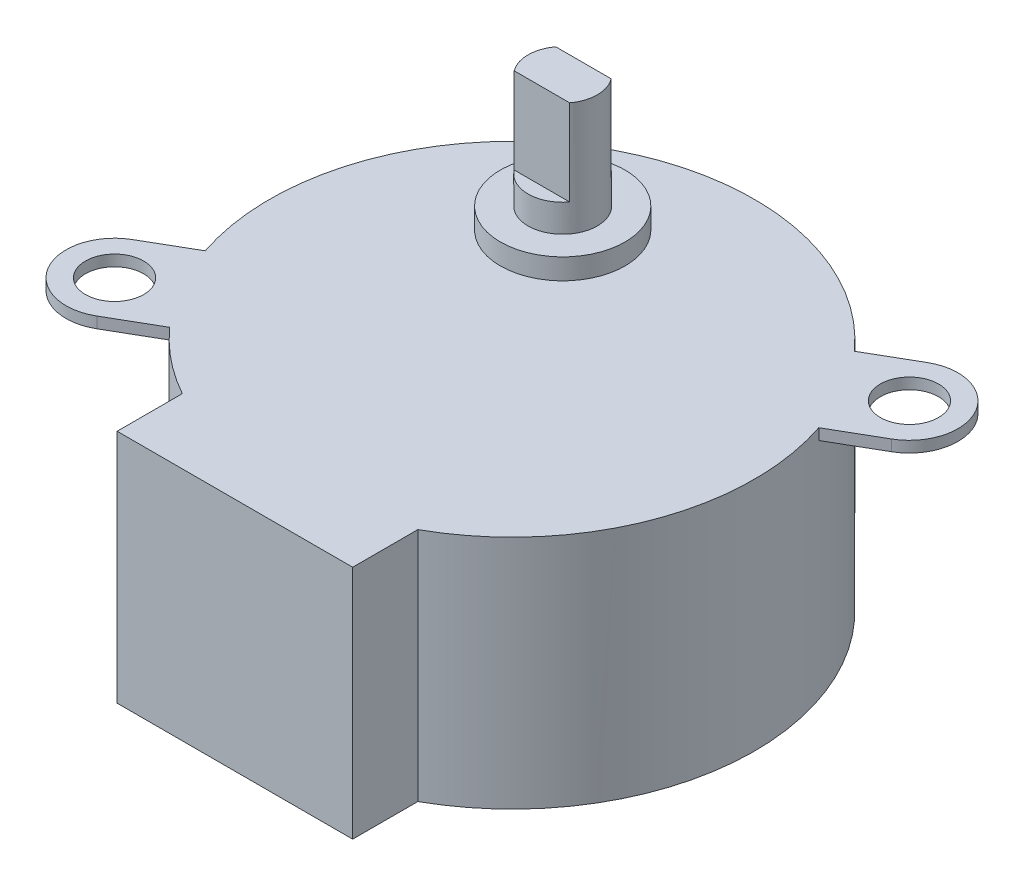
from build123d import *

# Parameters (mm, degrees)
SKETCH1_R           = 2.1
BOSS_EXTRUDE2_DEPTH = 17
SKETCH4_R           = 4.5
BOSS_EXTRUDE3_DEPTH = 1.5
SKETCH5_R           = 2.5
BOSS_EXTRUDE4_DEPTH = 2
SKETCH8_R           = 2.1
CUT_EXTRUDE1_DEPTH  = 16.2
BOSS_EXTRUDE6_DEPTH = 6.2


with BuildPart() as part:
    # Sketch1 → Boss-Extrude2 (new body)
    with BuildSketch(Plane(origin=(0, 0, 0), x_dir=(1, 0, 0), z_dir=(0, 1, 0))):
        with BuildLine():
            Line((-8.5, -20), (8.5, -20))
            Line((8.5, -20), (8.5, -15.297058541))
            ThreePointArc((8.5, -15.297058541), (16.311372932, -6.339488392), (16.599242405, 5.542125186))
            Line((16.599242405, 5.542125186), (19.936533479, 7.468911087))
            ThreePointArc((19.936533479, 7.468911087), (21.217622393, 12.25), (16.436533479, 13.531088913))
            Line((16.436533479, 13.531088913), (13.099242405, 11.604303013))
            ThreePointArc((13.099242405, 11.604303013), (-8.75, 15.155444566), (-16.599242405, -5.542125186))
            Line((-16.599242405, -5.542125186), (-19.936533479, -7.468911087))
            ThreePointArc((-19.936533479, -7.468911087), (-21.217622393, -12.25), (-16.436533479, -13.531088913))
            Line((-16.436533479, -13.531088913), (-13.099242405, -11.604303013))
            ThreePointArc((-13.099242405, -11.604303013), (-10.956319134, -13.64584446), (-8.5, -15.297058541))
            Line((-8.5, -15.297058541), (-8.5, -20))
        make_face()
        with Locations((-18.186533479, -10.5)):
            Circle(SKETCH1_R, mode=Mode.SUBTRACT)
        with Locations((18.186533479, 10.5)):
            Circle(SKETCH1_R, mode=Mode.SUBTRACT)
    extrude(amount=BOSS_EXTRUDE2_DEPTH)

    # Sketch4 → Boss-Extrude3 (add)
    with BuildSketch(Plane(origin=(0, 17, 0), x_dir=(1, 0, 0), z_dir=(0, 1, 0))):
        with Locations((-5, 8.660254038)):
            Circle(SKETCH4_R)
    extrude(amount=BOSS_EXTRUDE3_DEPTH)

    # Sketch5 → Boss-Extrude4 (add)
    with BuildSketch(Plane(origin=(0, 18.5, 0), x_dir=(1, 0, 0), z_dir=(0, 1, 0))):
        with Locations((-5, 8.660254038)):
            Circle(SKETCH5_R)
    extrude(amount=BOSS_EXTRUDE4_DEPTH)

    # Sketch8 → Cut-Extrude1 (cut)
    with BuildSketch(Plane.XZ):
        with BuildLine():
            ThreePointArc((16.599242405, -5.542125186), (15.155444566, -8.75), (13.099242405, -11.604303013))
            Line((13.099242405, -11.604303013), (16.436533479, -13.531088913))
            ThreePointArc((16.436533479, -13.531088913), (21.217622393, -12.25), (19.936533479, -7.468911087))
            Line((19.936533479, -7.468911087), (16.599242405, -5.542125186))
        make_face()
        with Locations((18.186533479, -10.5)):
            Circle(SKETCH8_R, mode=Mode.SUBTRACT)
        with BuildLine():
            ThreePointArc((-13.099242405, 11.604303013), (-15.155444566, 8.75), (-16.599242405, 5.542125186))
            Line((-16.599242405, 5.542125186), (-19.936533479, 7.468911087))
            ThreePointArc((-19.936533479, 7.468911087), (-21.217622393, 12.25), (-16.436533479, 13.531088913))
            Line((-16.436533479, 13.531088913), (-13.099242405, 11.604303013))
        make_face()
        with Locations((-18.186533479, 10.5)):
            Circle(SKETCH8_R, mode=Mode.SUBTRACT)
    extrude(amount=-CUT_EXTRUDE1_DEPTH, mode=Mode.SUBTRACT)

    # Sketch9 → Boss-Extrude6 (add)
    with BuildSketch(Plane(origin=(0, 20.5, 0), x_dir=(1, 0, 0), z_dir=(0, 1, 0))):
        with BuildLine():
            Line((-7, 7.160254038), (-3, 7.160254038))
            ThreePointArc((-3, 7.160254038), (-2.5, 8.660254038), (-3, 10.160254038))
            Line((-3, 10.160254038), (-7, 10.160254038))
            ThreePointArc((-7, 10.160254038), (-7.5, 8.660254038), (-7, 7.160254038))
        make_face()
    extrude(amount=BOSS_EXTRUDE6_DEPTH)


solid = part.part
